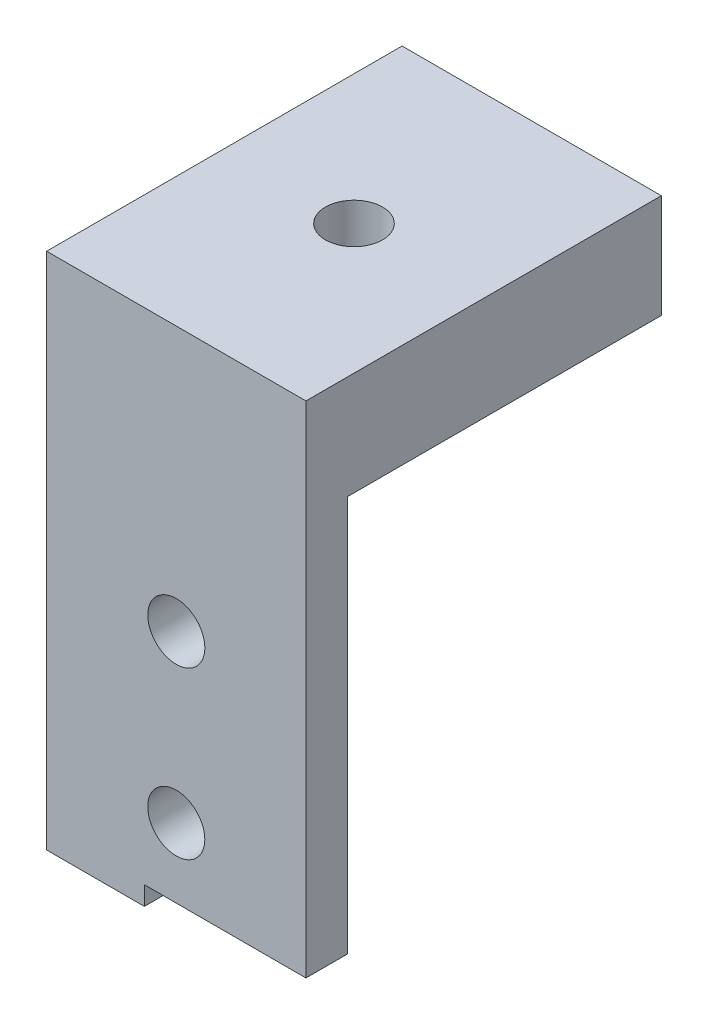
from build123d import *

# Parameters (mm, degrees)
SKETCH1_W                  = 12.5
SKETCH1_H                  = 17.135
TABBASE_DEPTH              = 5
SKETCH2_R                  = 1.375
CHASSISMOUNTINGHOLE_DEPTH  = 5
SKETCH3_W                  = 12.5
SKETCH3_H                  = 26
FRONTTAB_DEPTH             = 5
FRONTMOUNTINGHOLESSKETCH_R = 1.375
FRONTMOUNTINGHOLES_DEPTH   = 5
SKETCH4_W                  = 12.5
SKETCH4_H                  = 21
SKETCH4_R                  = 1.375
CUT_EXTRUDE1_DEPTH         = 3
SKETCH6_W                  = 7.78949329
SKETCH6_H                  = 1.90597399
CUT_EXTRUDE2_DEPTH         = 10
SKETCH7_W                  = 4.71050671
SKETCH7_H                  = 1
CUT_EXTRUDE3_DEPTH         = 10


with BuildPart() as part:
    # Sketch1 → tabBase (new body)
    with BuildSketch(Plane(origin=(0, 0, 0), x_dir=(1, 0, 0), z_dir=(0, 1, 0))):
        with Locations((6.25, 8.5675)):
            Rectangle(SKETCH1_W, SKETCH1_H)
    extrude(amount=TABBASE_DEPTH)

    # Sketch2 → chassisMountingHole (cut)
    with BuildSketch(Plane(origin=(0, 5, 0), x_dir=(1, 0, 0), z_dir=(0, 1, 0))):
        with Locations((6.25, 8.5675)):
            Circle(SKETCH2_R)
    extrude(amount=-CHASSISMOUNTINGHOLE_DEPTH, mode=Mode.SUBTRACT)

    # Sketch3 → frontTab (add)
    with BuildSketch(Plane.XY):
        with Locations((6.25, -8)):
            Rectangle(SKETCH3_W, SKETCH3_H)
    extrude(amount=-FRONTTAB_DEPTH)

    # frontMountingHolesSketch → frontMountingHoles (cut)
    with BuildSketch(Plane(origin=(0, 0, -5), x_dir=(-1, 0, 0), z_dir=(0, 0, -1))):
        with Locations((-6.25, -15.75)):
            Circle(FRONTMOUNTINGHOLESSKETCH_R)
        with Locations((-6.25, -7.75)):
            Circle(FRONTMOUNTINGHOLESSKETCH_R)
    extrude(amount=-FRONTMOUNTINGHOLES_DEPTH, mode=Mode.SUBTRACT)

    # Sketch4 → Cut-Extrude1 (cut)
    with BuildSketch(Plane(origin=(0, 0, -5), x_dir=(-1, 0, 0), z_dir=(0, 0, -1))):
        with Locations((-6.25, -10.5)):
            Rectangle(SKETCH4_W, SKETCH4_H)
        with Locations((-6.25, -15.75)):
            Circle(SKETCH4_R, mode=Mode.SUBTRACT)
        with Locations((-6.25, -7.75)):
            Circle(SKETCH4_R, mode=Mode.SUBTRACT)
    extrude(amount=-CUT_EXTRUDE1_DEPTH, mode=Mode.SUBTRACT)

    # Sketch6 → Cut-Extrude2 (cut)
    with BuildSketch(Plane(origin=(0, 0, -2), x_dir=(-1, 0, 0), z_dir=(0, 0, -1))):
        with Locations((-8.605253355, -20.047013005)):
            Rectangle(SKETCH6_W, SKETCH6_H)
    extrude(amount=-CUT_EXTRUDE2_DEPTH, mode=Mode.SUBTRACT)

    # Sketch7 → Cut-Extrude3 (cut)
    with BuildSketch(Plane(origin=(0, 0, -2), x_dir=(-1, 0, 0), z_dir=(0, 0, -1))):
        with Locations((-2.355253355, -20.5)):
            Rectangle(SKETCH7_W, SKETCH7_H)
    extrude(amount=-CUT_EXTRUDE3_DEPTH, mode=Mode.SUBTRACT)


solid = part.part
